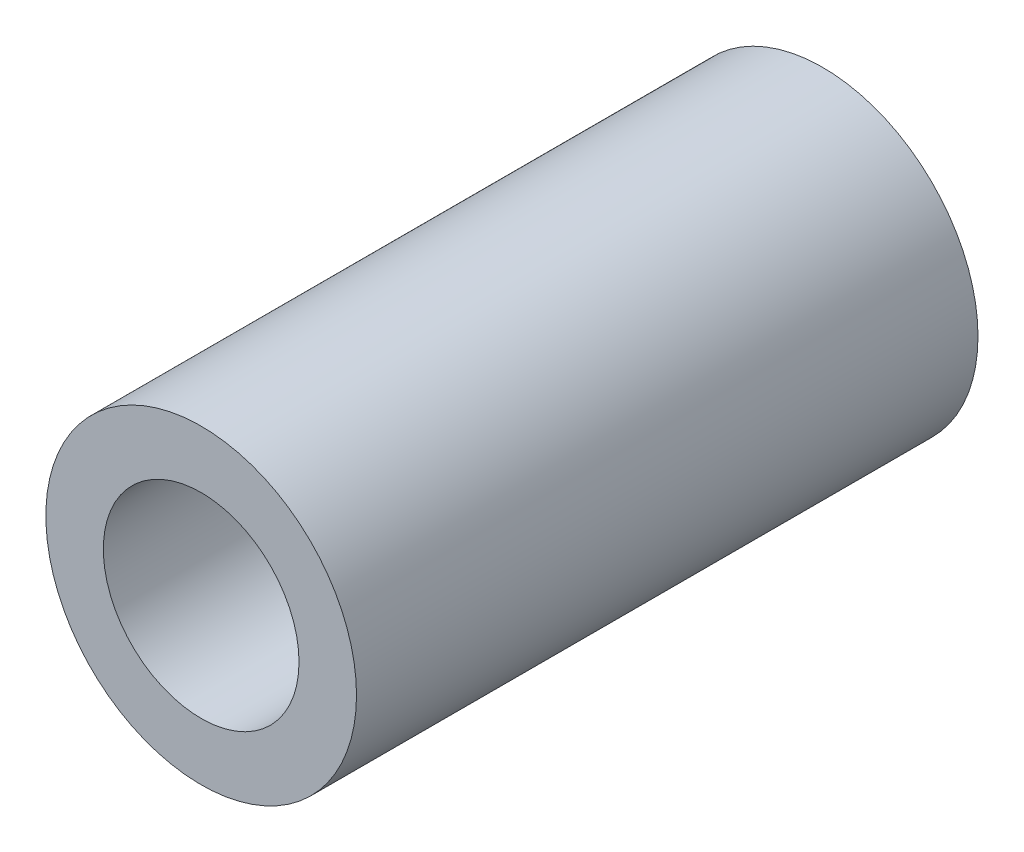
from build123d import *

# Parameters (mm, degrees)
SKETCH1_R           = 2.38125
SKETCH1_R_2         = 1.5
BOSS_EXTRUDE1_DEPTH = 4.763750061


with BuildPart() as part:
    # Sketch1 → Boss-Extrude1 (new body, symmetric)
    with BuildSketch(Plane.XY):
        Circle(SKETCH1_R)
        Circle(SKETCH1_R_2, mode=Mode.SUBTRACT)
    extrude(amount=BOSS_EXTRUDE1_DEPTH, both=True)


solid = part.part
